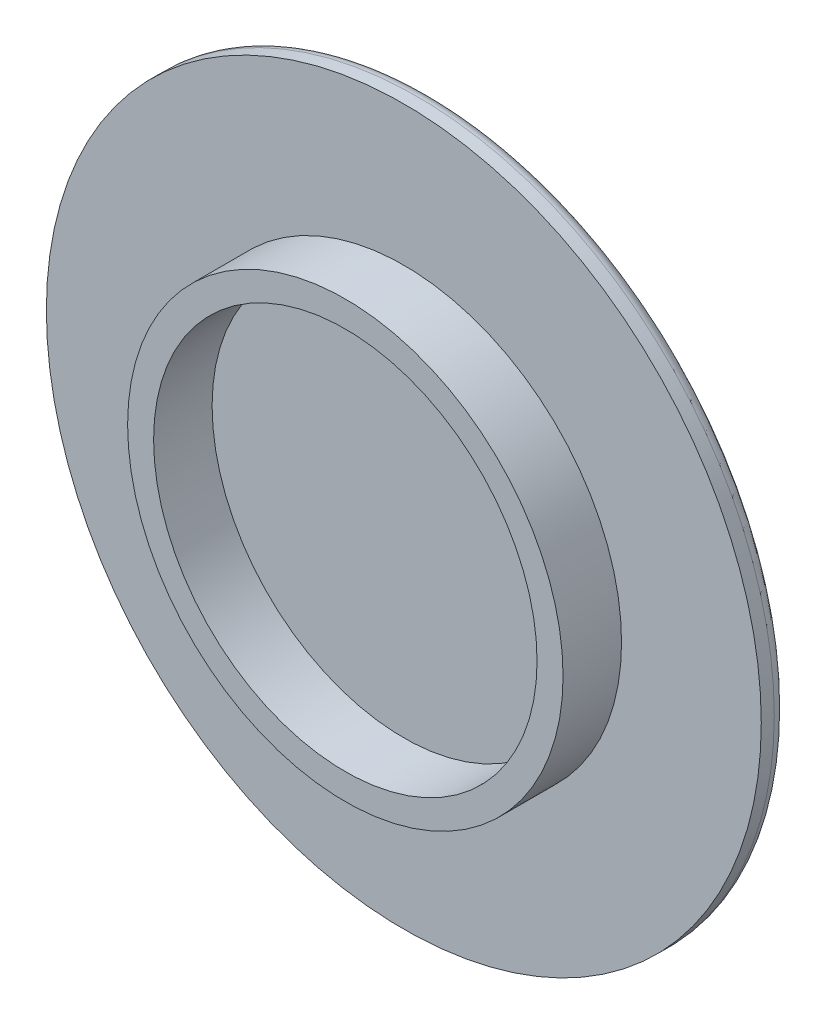
from build123d import *

# Parameters (mm, degrees)
CROQUIS1_R           = 16.75
CROQUIS1_R_2         = 14.75
PESTA_AENTRADA_DEPTH = 4.5
CROQUIS2_R           = 27.5
TAPADERA_DEPTH       = 2
DETALLESUPERIOR_R    = 1


with BuildPart() as part:
    # Croquis1 → PestañaEntrada (new body)
    with BuildSketch(Plane.XY):
        Circle(CROQUIS1_R)
        Circle(CROQUIS1_R_2, mode=Mode.SUBTRACT)
    extrude(amount=PESTA_AENTRADA_DEPTH)

    # Croquis2 → Tapadera (add)
    with BuildSketch(Plane(origin=(0, 0, 0), x_dir=(-1, 0, 0), z_dir=(0, 0, -1))):
        Circle(CROQUIS2_R)
    extrude(amount=TAPADERA_DEPTH)

    # DetalleSuperior
    detallesuperior_edges = [part.edges().sort_by_distance(p)[0] for p in [
        (27.5, 0, -2),
    ]]
    fillet(detallesuperior_edges, radius=DETALLESUPERIOR_R)


solid = part.part
